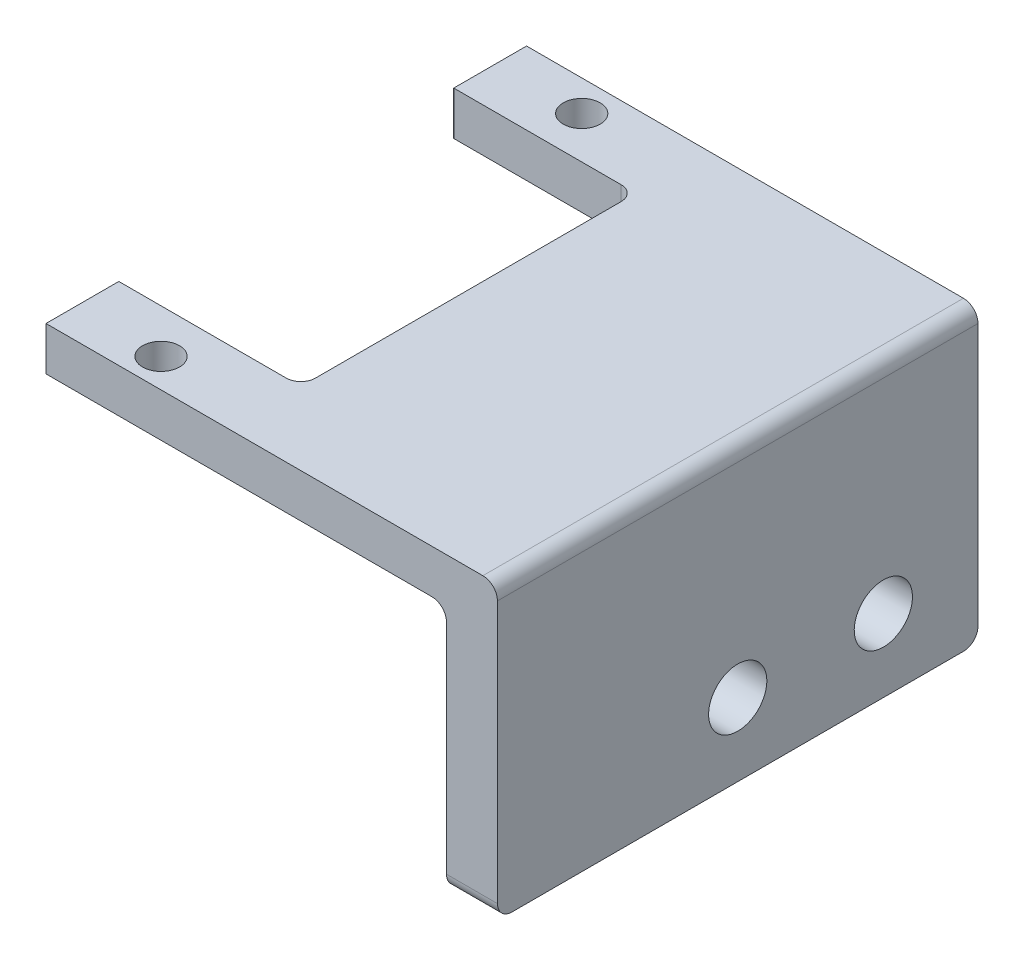
from build123d import *

# Parameters (mm, degrees)
SKETCH1_W             = 15
SKETCH1_H             = 5
SKETCH1_R             = 1.27
BOSS_EXTRUDE1_DEPTH   = 3
BOSS_EXTRUDE1_2_DEPTH = 3
SKETCH2_W             = 2.5
SKETCH2_H             = 28
SKETCH2_H_2           = 5
BOSS_EXTRUDE2_DEPTH   = 20
SKETCH3_W             = 15
SKETCH3_H             = 17
CUT_EXTRUDE1_DEPTH    = 34
SKETCH4_R             = 2
CUT_EXTRUDE2_DEPTH    = 4.5
FILLET1_R             = 1


with BuildPart() as part:
    # Sketch1 → Boss-Extrude1 (new body)
    with BuildSketch(Plane(origin=(0, -5.173201946, 0), x_dir=(1, 0, 0), z_dir=(0, 1, 0))):
        with Locations((7.5, -2.5)):
            Rectangle(SKETCH1_W, SKETCH1_H)
        with Locations((5.906433977, -2.119480538)):
            Circle(SKETCH1_R, mode=Mode.SUBTRACT)
    extrude(amount=BOSS_EXTRUDE1_DEPTH)



with BuildPart() as body_2:
    # Sketch1 → Boss-Extrude1 2 (new body)
    with BuildSketch(Plane(origin=(0, -5.173201946, 0), x_dir=(1, 0, 0), z_dir=(0, 1, 0))):
        with Locations((7.5, -30.5)):
            Rectangle(SKETCH1_W, SKETCH1_H)
        with Locations((5.906433977, -31.007519462)):
            Circle(SKETCH1_R, mode=Mode.SUBTRACT)
    extrude(amount=BOSS_EXTRUDE1_2_DEPTH)


with BuildPart() as part_1:
    add(part.part)

    add(body_2.part)  # Boss-Extrude2 merges body 2
    # Sketch2 → Boss-Extrude2 (add)
    with BuildSketch(Plane(origin=(0, -2.173201946, 0), x_dir=(1, 0, 0), z_dir=(0, 1, 0))):
        with Locations((13.75, -14)):
            Rectangle(SKETCH2_W, SKETCH2_H)
        Polygon((31, 0), (15, 0), (15, -28), (15, -33), (31, -33), align=None)
        with Locations((13.75, -30.5)):
            Rectangle(SKETCH2_W, SKETCH2_H_2)
    extrude(amount=-BOSS_EXTRUDE2_DEPTH)

    # Sketch3 → Cut-Extrude1 (cut, through all)
    with BuildSketch(Plane(origin=(0, 0, 0), x_dir=(-1, 0, 0), z_dir=(0, 0, -1))):
        with Locations((-20, -13.673201946)):
            Rectangle(SKETCH3_W, SKETCH3_H)
    extrude(amount=-CUT_EXTRUDE1_DEPTH, mode=Mode.SUBTRACT)

    # Sketch4 → Cut-Extrude2 (cut, through all)
    with BuildSketch(Plane.ZY.offset(-27.5)):
        with Locations((16.5, -17.173201946)):
            Circle(SKETCH4_R)
        with Locations((6.5, -17.173201946)):
            Circle(SKETCH4_R)
    extrude(amount=-CUT_EXTRUDE2_DEPTH, mode=Mode.SUBTRACT)

    # Fillet1
    fillet1_edges = [part_1.edges().sort_by_distance(p)[0] for p in [
        (12.5, -3.673201946, 5),
        (31, -2.173201946, 16.5),
        (12.5, -3.673201946, 28),
        (29.25, -22.173201946, 33),
        (29.25, -22.173201946, 0),
        (27.5, -5.173201946, 16.5),
    ]]
    fillet(fillet1_edges, radius=FILLET1_R)


solid = part_1.part
